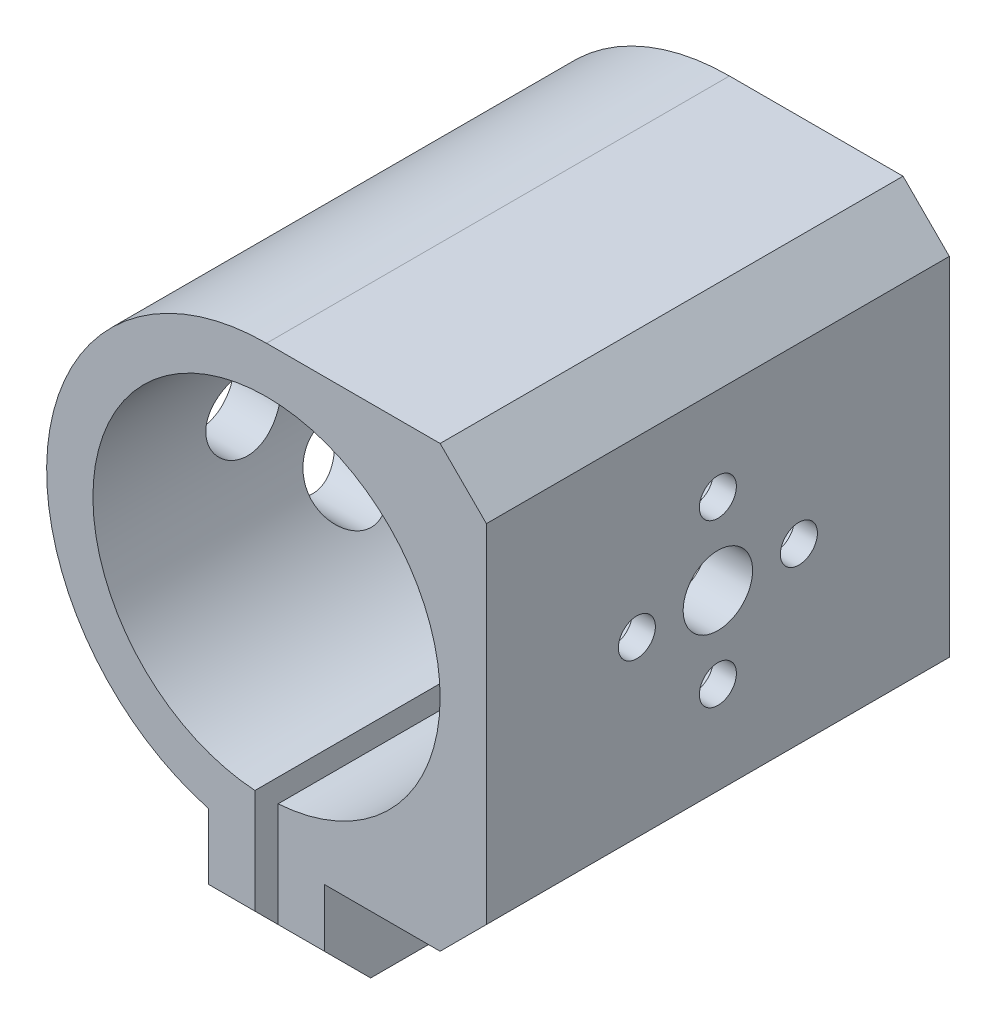
from build123d import *

# Parameters (mm, degrees)
EXTRUDE_1_DEPTH          = 40
SKETCH_2_W               = 10
SKETCH_2_H               = 28
EXTRUDE_2_DEPTH          = 15
CUT_EXTRUDE_1_REACH      = 42
SKETCH_3_R               = 15
SKETCH_4_W               = 14
SKETCH_4_H               = 4
CUT_EXTRUDE_2_DEPTH      = 20
CUT_EXTRUDE_3_REACH      = 42
SKETCH_5_W               = 2
SKETCH_5_H               = 30
SKETCH_6_R               = 11
CUT_EXTRUDE_4_DEPTH      = 20
SKETCH_7_R               = 3
CUT_EXTRUDE_5_DEPTH      = 39.0000001
SKETCH_14_R              = 1.6
CUT_EXTRUDE_6_DEPTH      = 10
SKETCH_15_R              = 3.25
CUT_EXTRUDE_7_DEPTH      = 37.0000001
PATTERN_CIRCULAR_1_COUNT = 4
CHAMFER_1_SIZE           = 4
SKETCH_16_R              = 2.25
CUT_EXTRUDE_8_DEPTH      = 25.0000001
SKETCH_17_W              = 22
SKETCH_17_H              = 12.4
CUT_EXTRUDE_10_DEPTH     = 10


with BuildPart() as part:
    # 草圖1 → 填料-伸長1 (new body)
    with BuildSketch(Plane.XY):
        with BuildLine():
            Line((0, 19), (19, 19))
            Line((19, 19), (19, -19))
            Line((19, -19), (0, -19))
            ThreePointArc((0, -19), (-19, 0), (0, 19))
        make_face()
    extrude(amount=EXTRUDE_1_DEPTH)

    # 草圖2 → 填料-伸長2 (add)
    with BuildSketch(Plane.XY.offset(40)):
        with Locations((0, -14)):
            Rectangle(SKETCH_2_W, SKETCH_2_H)
    extrude(amount=-EXTRUDE_2_DEPTH)

    # 草圖3 → 除料-伸長1 (cut, up to next)
    with BuildSketch(Plane.XY.offset(40), mode=Mode.PRIVATE) as cut_extrude_1_sk1:
        Circle(SKETCH_3_R)
    cut_extrude_1_tool1 = extrude(cut_extrude_1_sk1.sketch, amount=-CUT_EXTRUDE_1_REACH, mode=Mode.PRIVATE) & part.part
    add(cut_extrude_1_tool1.solids().sort_by_distance((0, 0, 40))[0], mode=Mode.SUBTRACT)

    # 草圖4 → 除料-伸長2 (cut)
    with BuildSketch(Plane(origin=(0, 0, 0), x_dir=(-1, 0, 0), z_dir=(0, 0, -1))):
        with Locations((0, 14)):
            Rectangle(SKETCH_4_W, SKETCH_4_H)
    extrude(amount=-CUT_EXTRUDE_2_DEPTH, mode=Mode.SUBTRACT)

    # 草圖5 → 除料-伸長3 (cut, up to next)
    with BuildSketch(Plane(origin=(0, 0, 0), x_dir=(-1, 0, 0), z_dir=(0, 0, -1)), mode=Mode.PRIVATE) as cut_extrude_3_sk1:
        with Locations((0, -15)):
            Rectangle(SKETCH_5_W, SKETCH_5_H)
    cut_extrude_3_tool1 = extrude(cut_extrude_3_sk1.sketch, amount=-CUT_EXTRUDE_3_REACH, mode=Mode.PRIVATE) & part.part
    add(cut_extrude_3_tool1.solids().sort_by_distance((0, -15, 0))[0], mode=Mode.SUBTRACT)

    # 草圖6 → 除料-伸長4 (cut)
    with BuildSketch(Plane(origin=(0, -19, 0), x_dir=(-1, 0, 0), z_dir=(0, -1, 0))):
        with Locations((0, -6)):
            Circle(SKETCH_6_R)
    extrude(amount=-CUT_EXTRUDE_4_DEPTH, mode=Mode.SUBTRACT)

    # 草圖7 → 除料-伸長5 (cut, through all)
    with BuildSketch(Plane(origin=(19, 0, 0), x_dir=(0, 0, -1), z_dir=(1, 0, 0))):
        with Locations((-20, 0)):
            Circle(SKETCH_7_R)
    extrude(amount=-CUT_EXTRUDE_5_DEPTH, mode=Mode.SUBTRACT)

    # 草圖14 → 除料-伸長6 (cut)
    with BuildSketch(Plane(origin=(19, 0, 0), x_dir=(0, 0, -1), z_dir=(1, 0, 0))):
        with Locations((-20, 7)):
            Circle(SKETCH_14_R)
    cut_extrude_6 = extrude(amount=-CUT_EXTRUDE_6_DEPTH, mode=Mode.SUBTRACT)

    # 草圖15 → 除料-伸長7 (cut, through all)
    with BuildSketch(Plane(origin=(17, 0, 0), x_dir=(0, 0, -1), z_dir=(1, 0, 0))):
        with Locations((-20, 7)):
            Circle(SKETCH_15_R)
    cut_extrude_7 = extrude(amount=-CUT_EXTRUDE_7_DEPTH, mode=Mode.SUBTRACT)

    # 環狀複製排列1: 除料-伸長6, 除料-伸長7 ×4 about axis
    pattern_circular_1_axis = Axis((0, 0, 20), (1, 0, 0))
    for i in range(1, PATTERN_CIRCULAR_1_COUNT):
        add(cut_extrude_6.rotate(pattern_circular_1_axis, i * 360 / PATTERN_CIRCULAR_1_COUNT), mode=Mode.SUBTRACT)
        add(cut_extrude_7.rotate(pattern_circular_1_axis, i * 360 / PATTERN_CIRCULAR_1_COUNT), mode=Mode.SUBTRACT)

    # 導角1
    chamfer_1_edges = [part.edges().sort_by_distance(p)[0] for p in [
        (-3, -28, 40),
        (-3, -28, 25),
        (3, -28, 40),
        (3, -28, 25),
        (19, 19, 20),
        (19, -19, 20),
    ]]
    chamfer(chamfer_1_edges, length=CHAMFER_1_SIZE)

    # 草圖16 → 除料-伸長8 (cut, through all)
    with BuildSketch(Plane.ZY.offset(5)):
        with Locations((32.5, -23)):
            Circle(SKETCH_16_R)
    extrude(amount=-CUT_EXTRUDE_8_DEPTH, mode=Mode.SUBTRACT)

    # 草圖17 → 除料-伸長10 (cut)
    with BuildSketch(Plane(origin=(0, -19, 0), x_dir=(-1, 0, 0), z_dir=(0, -1, 0))):
        Rectangle(SKETCH_17_W, SKETCH_17_H)
    extrude(amount=-CUT_EXTRUDE_10_DEPTH, mode=Mode.SUBTRACT)


solid = part.part
